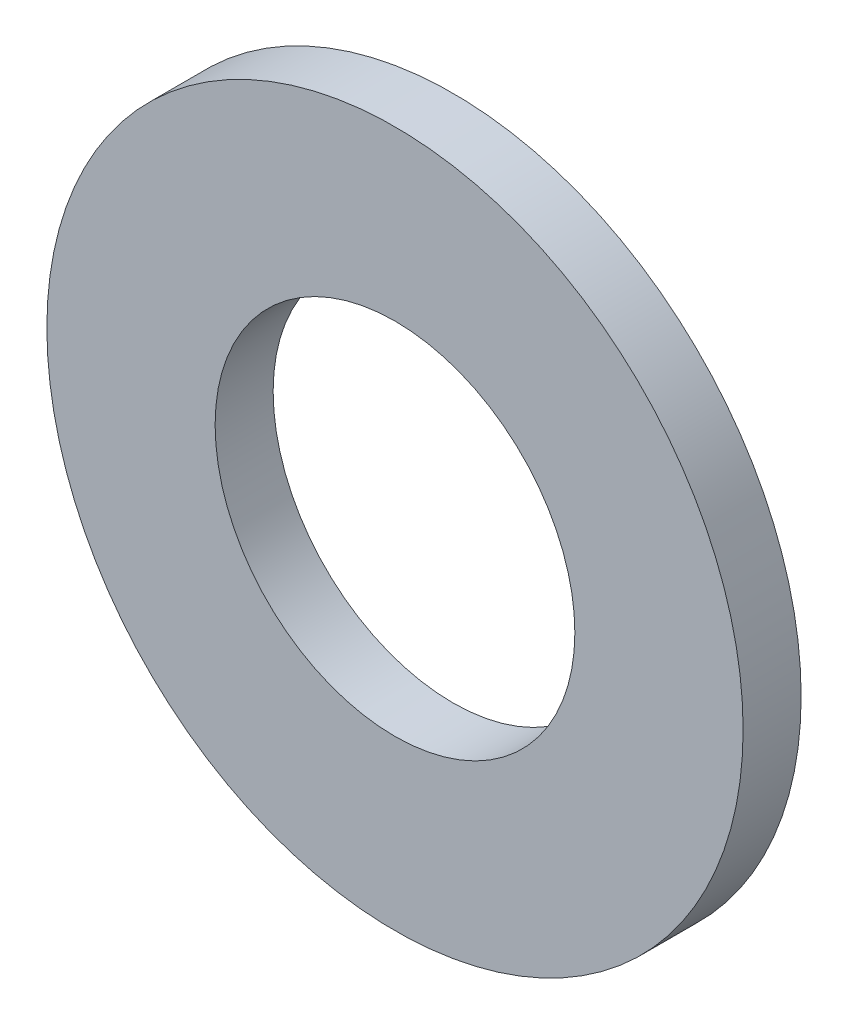
from build123d import *

# Parameters (mm, degrees)
SKETCH1_R           = 3
SKETCH1_R_2         = 1.55
BOSS_EXTRUDE1_DEPTH = 0.5


with BuildPart() as part:
    # Sketch1 → Boss-Extrude1 (new body)
    with BuildSketch(Plane.XY):
        Circle(SKETCH1_R)
        Circle(SKETCH1_R_2, mode=Mode.SUBTRACT)
    extrude(amount=BOSS_EXTRUDE1_DEPTH)


solid = part.part
